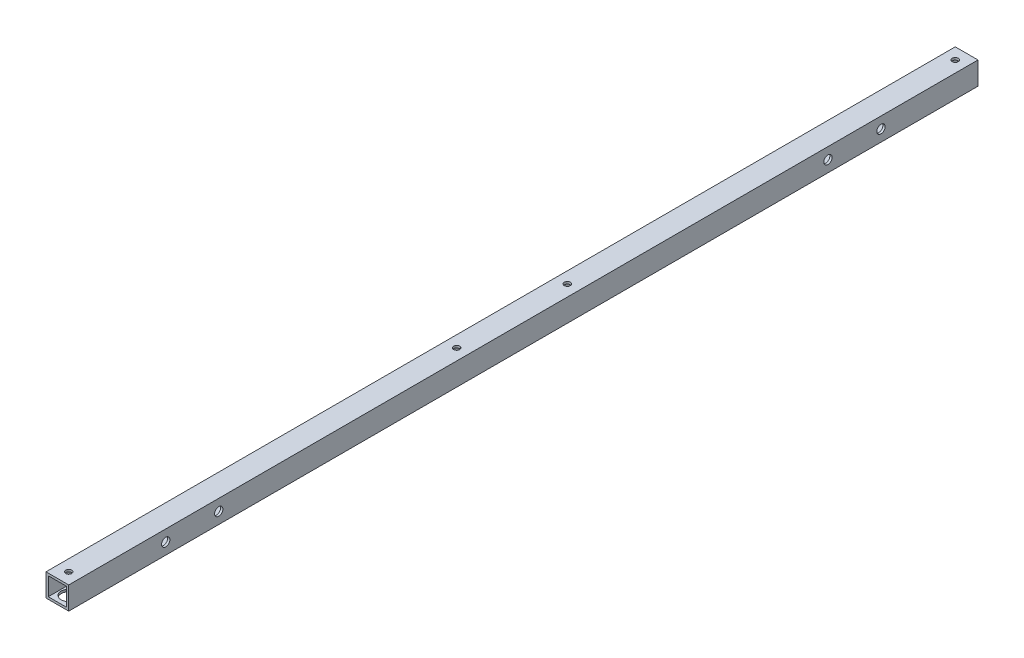
from build123d import *

# Parameters (mm, degrees)
SKETCH_1_W          = 15
SKETCH_1_H          = 15
SKETCH_1_W_2        = 12
SKETCH_1_H_2        = 12
EXTRUDE_1_DEPTH     = 600
SKETCH_3_R          = 2
CUT_EXTRUDE_2_DEPTH = 25
SKETCH_4_R          = 2.75
CUT_EXTRUDE_3_DEPTH = 20
SKETCH_6_R          = 2
CUT_EXTRUDE_4_DEPTH = 20
SKETCH_9_R          = 5
CUT_EXTRUDE_7_DEPTH = 10


with BuildPart() as part:
    # ｽｹｯﾁ1 → ﾎﾞｽ - 押し出し1 (new body)
    with BuildSketch(Plane.XY):
        Rectangle(SKETCH_1_W, SKETCH_1_H)
        Rectangle(SKETCH_1_W_2, SKETCH_1_H_2, mode=Mode.SUBTRACT)
    extrude(amount=EXTRUDE_1_DEPTH)

    # ｽｹｯﾁ3 → ｶｯﾄ - 押し出し2 (cut)
    with BuildSketch(Plane(origin=(0, 7.5, 0), x_dir=(1, 0, 0), z_dir=(0, 1, 0))):
        with Locations((0, -7.5)):
            Circle(SKETCH_3_R)
        with Locations((0, -592.5)):
            Circle(SKETCH_3_R)
    extrude(amount=-CUT_EXTRUDE_2_DEPTH, mode=Mode.SUBTRACT)

    # ｽｹｯﾁ4 → ｶｯﾄ - 押し出し3 (cut)
    with BuildSketch(Plane(origin=(7.5, 0, 0), x_dir=(0, 0, -1), z_dir=(1, 0, 0))):
        with Locations((-536, 0)):
            Circle(SKETCH_4_R)
        with Locations((-501, 0)):
            Circle(SKETCH_4_R)
        with Locations((-99, 0)):
            Circle(SKETCH_4_R)
        with Locations((-64, 0)):
            Circle(SKETCH_4_R)
    extrude(amount=-CUT_EXTRUDE_3_DEPTH, mode=Mode.SUBTRACT)

    # ｽｹｯﾁ6 → ｶｯﾄ - 押し出し4 (cut)
    with BuildSketch(Plane(origin=(0, 7.5, 0), x_dir=(1, 0, 0), z_dir=(0, 1, 0))):
        with Locations((0, -336.5)):
            Circle(SKETCH_6_R)
        with Locations((0, -263.5)):
            Circle(SKETCH_6_R)
    extrude(amount=-CUT_EXTRUDE_4_DEPTH, mode=Mode.SUBTRACT)

    # ｽｹｯﾁ9 → ｶｯﾄ - 押し出し7 (cut)
    with BuildSketch(Plane.XZ.offset(7.5)):
        with Locations((0, 592.5)):
            Circle(SKETCH_9_R)
        with Locations((0, 336.5)):
            Circle(SKETCH_9_R)
        with Locations((0, 263.5)):
            Circle(SKETCH_9_R)
        with Locations((0, 7.5)):
            Circle(SKETCH_9_R)
    extrude(amount=-CUT_EXTRUDE_7_DEPTH, mode=Mode.SUBTRACT)


solid = part.part
